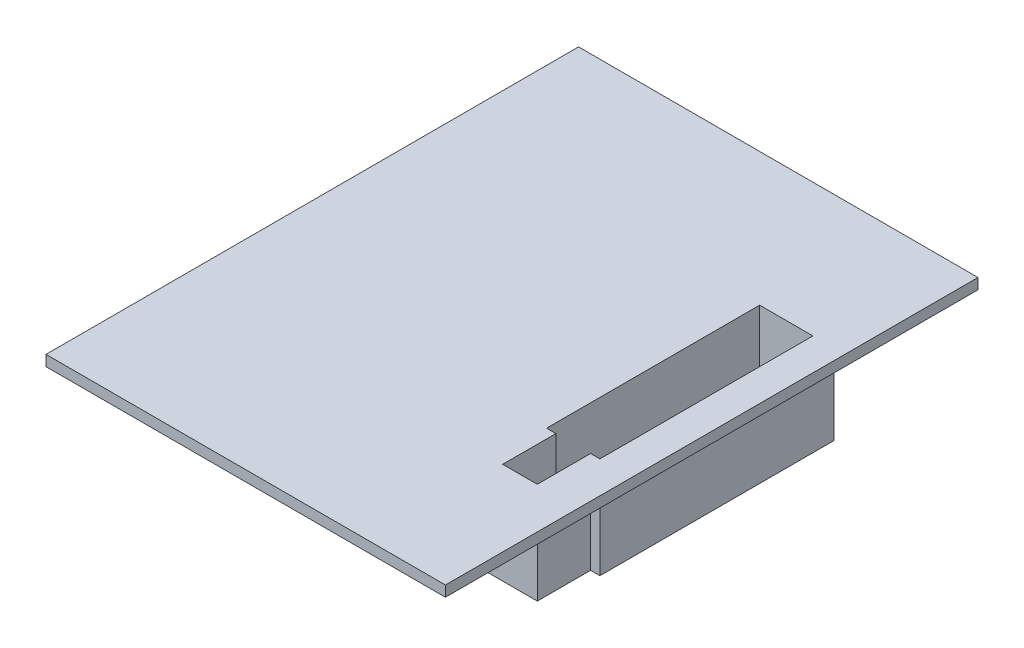
from build123d import *

# Parameters (mm, degrees)
SKETCH1_W               = 75
SKETCH1_H               = 100
BOSS_EXTRUDE1_DEPTH     = 2
CUT_EXTRUDE1_REACH      = 4
SKETCH2_W               = 10
SKETCH2_H               = 50
SKETCH3_W               = 1.75
SKETCH3_H               = 10
BOSS_EXTRUDE2_DEPTH     = 2
BOSS_EXTRUDE3_DEPTH     = 15
SKETCH5_R               = 1.75
CUT_EXTRUDE2_DEPTH      = 65
CUT_EXTRUDE2_DEPTH_BACK = 12


with BuildPart() as part:
    # Sketch1 → Boss-Extrude1 (new body)
    with BuildSketch(Plane(origin=(0, 0, 0), x_dir=(1, 0, 0), z_dir=(0, 1, 0))):
        Rectangle(SKETCH1_W, SKETCH1_H)
    extrude(amount=BOSS_EXTRUDE1_DEPTH)

    # Sketch2 → Cut-Extrude1 (cut, up to next)
    with BuildSketch(Plane(origin=(0, 2, 0), x_dir=(1, 0, 0), z_dir=(0, 1, 0)), mode=Mode.PRIVATE) as cut_extrude1_sk1:
        with Locations((26.5, 0)):
            Rectangle(SKETCH2_W, SKETCH2_H)
    cut_extrude1_tool1 = extrude(cut_extrude1_sk1.sketch, amount=-CUT_EXTRUDE1_REACH, mode=Mode.PRIVATE) & part.part
    add(cut_extrude1_tool1.solids().sort_by_distance((26.5, 2, 0))[0], mode=Mode.SUBTRACT)

    # Sketch3 → Boss-Extrude2 (add)
    with BuildSketch(Plane.XZ):
        with Locations((22.375, 20)):
            Rectangle(SKETCH3_W, SKETCH3_H)
        with Locations((30.625, 20)):
            Rectangle(SKETCH3_W, SKETCH3_H)
    extrude(amount=-BOSS_EXTRUDE2_DEPTH)

    # Sketch4 → Boss-Extrude3 (add)
    with BuildSketch(Plane.XZ):
        Polygon((33.5, 17), (31.75, 17), (31.75, 27), (21.25, 27), (21.25, 17), (19.5, 17), (19.5, -27), (33.5, -27), align=None)
        Polygon((31.5, 15), (29.75, 15), (29.75, 25), (23.25, 25), (23.25, 15), (21.5, 15), (21.5, -25), (31.5, -25), align=None, mode=Mode.SUBTRACT)
    extrude(amount=BOSS_EXTRUDE3_DEPTH)

    # Sketch5 → Cut-Extrude2 (cut, two sides)
    with BuildSketch(Plane.ZY.offset(-26.5)) as cut_extrude2_sk:
        with Locations((22, -3.5)):
            Circle(SKETCH5_R)
    extrude(amount=CUT_EXTRUDE2_DEPTH, mode=Mode.SUBTRACT)
    extrude(cut_extrude2_sk.sketch, amount=-CUT_EXTRUDE2_DEPTH_BACK, mode=Mode.SUBTRACT)


solid = part.part
